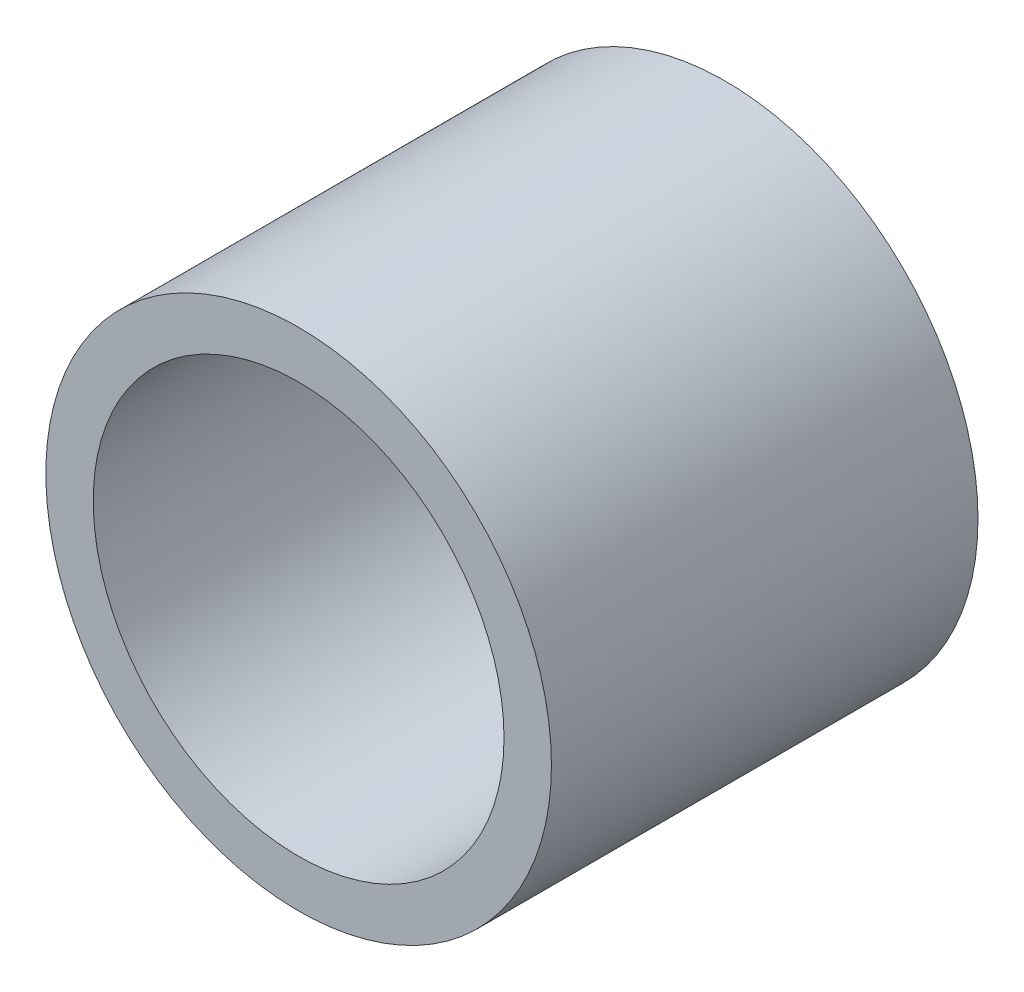
from build123d import *

# Parameters (mm, degrees)
SKETCH1_R           = 16
SKETCH1_R_2         = 13
BOSS_EXTRUDE1_DEPTH = 13.5


with BuildPart() as part:
    # Sketch1 → Boss-Extrude1 (new body, symmetric)
    with BuildSketch(Plane.XY):
        Circle(SKETCH1_R)
        Circle(SKETCH1_R_2, mode=Mode.SUBTRACT)
    extrude(amount=BOSS_EXTRUDE1_DEPTH, both=True)


solid = part.part
